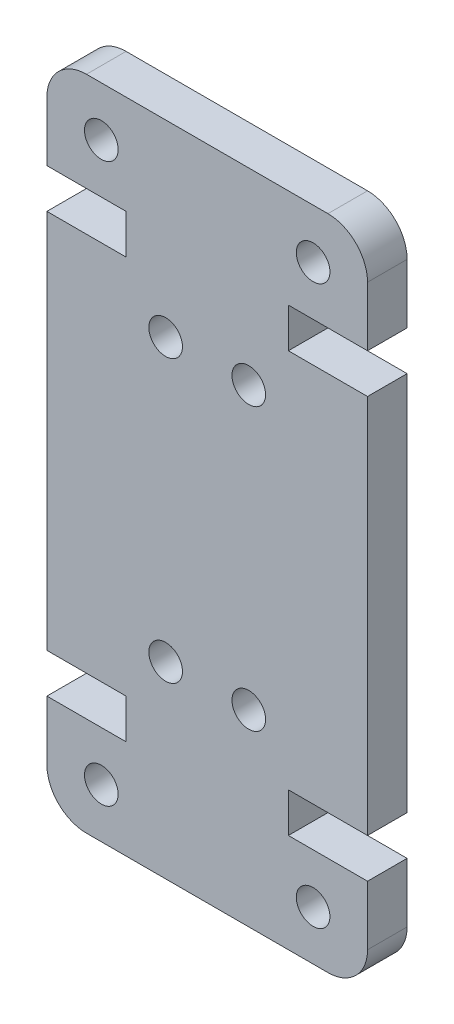
from build123d import *

# Parameters (mm, degrees)
SKETCH1_R           = 0.85
BOSS_EXTRUDE1_DEPTH = 4
SKETCH2_W           = 16.2
SKETCH2_H           = 33.21
CUT_EXTRUDE2_DEPTH  = 2


with BuildPart() as part:
    # Sketch1 → Boss-Extrude1 (new body)
    with BuildSketch(Plane.XY):
        with BuildLine():
            Line((0, 26.21), (0, 7))
            Line((0, 7), (4, 7))
            Line((4, 7), (4, 5))
            Line((4, 5), (0, 5))
            Line((0, 5), (0, 2))
            ThreePointArc((0, 2), (0.585786438, 0.585786438), (2, 0))
            Line((2, 0), (14.2, 0))
            ThreePointArc((14.2, 0), (15.614213562, 0.585786438), (16.2, 2))
            Line((16.2, 2), (16.2, 5))
            Line((16.2, 5), (12.2, 5))
            Line((12.2, 5), (12.2, 7))
            Line((12.2, 7), (16.2, 7))
            Line((16.2, 7), (16.2, 26.21))
            Line((16.2, 26.21), (12.2, 26.21))
            Line((12.2, 26.21), (12.2, 28.21))
            Line((12.2, 28.21), (16.2, 28.21))
            Line((16.2, 28.21), (16.2, 31.21))
            ThreePointArc((16.2, 31.21), (15.614213562, 32.624213562), (14.2, 33.21))
            Line((14.2, 33.21), (2, 33.21))
            ThreePointArc((2, 33.21), (0.585786438, 32.624213562), (0, 31.21))
            Line((0, 31.21), (0, 28.21))
            Line((0, 28.21), (4, 28.21))
            Line((4, 28.21), (4, 26.21))
            Line((4, 26.21), (0, 26.21))
        make_face()
        with Locations((13.45, 2.5)):
            Circle(SKETCH1_R, mode=Mode.SUBTRACT)
        with Locations((10.2, 9.5)):
            Circle(SKETCH1_R, mode=Mode.SUBTRACT)
        with Locations((2.75, 30.71)):
            Circle(SKETCH1_R, mode=Mode.SUBTRACT)
        with Locations((6, 23.71)):
            Circle(SKETCH1_R, mode=Mode.SUBTRACT)
        with Locations((6, 9.5)):
            Circle(SKETCH1_R, mode=Mode.SUBTRACT)
        with Locations((2.75, 2.5)):
            Circle(SKETCH1_R, mode=Mode.SUBTRACT)
        with Locations((10.2, 23.71)):
            Circle(SKETCH1_R, mode=Mode.SUBTRACT)
        with Locations((13.45, 30.71)):
            Circle(SKETCH1_R, mode=Mode.SUBTRACT)
    extrude(amount=BOSS_EXTRUDE1_DEPTH)

    # Sketch2 → Cut-Extrude2 (cut)
    with BuildSketch(Plane.XY):
        with Locations((8.1, 16.605)):
            Rectangle(SKETCH2_W, SKETCH2_H)
    extrude(amount=CUT_EXTRUDE2_DEPTH, mode=Mode.SUBTRACT)


solid = part.part
